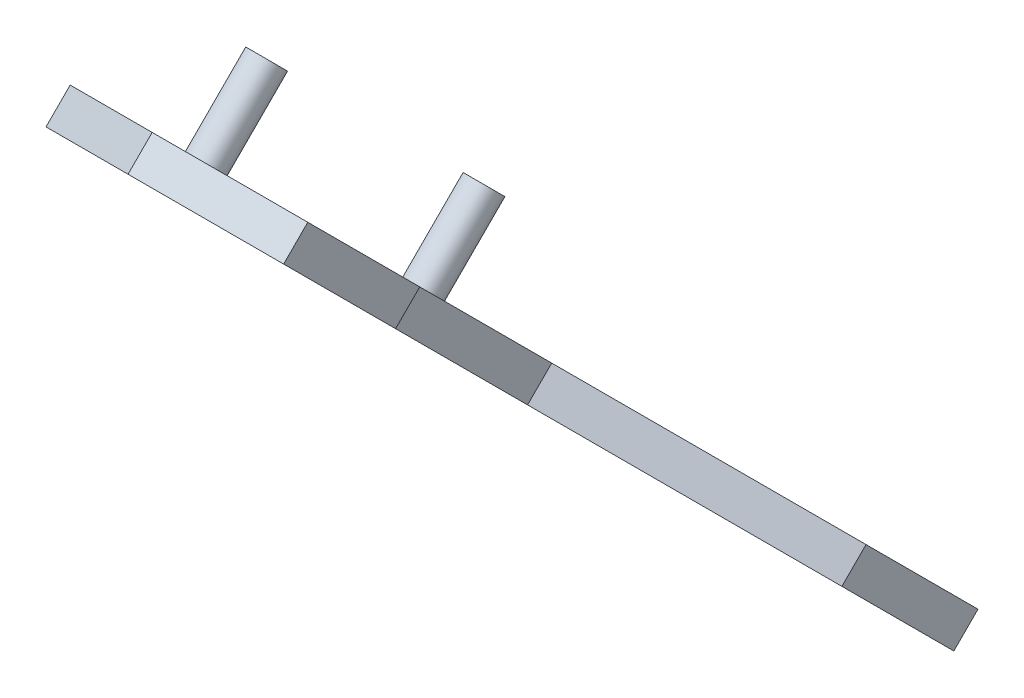
from build123d import *

# Parameters (mm, degrees)
BOSS_EXTRUDE1_DEPTH      = 5
BOSS_EXTRUDE1_DEPTH_BACK = 100
BOSS_EXTRUDE1_START      = -23110
SKETCH3_W                = 150.118051911
SKETCH3_H                = 92.714651823
BOSS_EXTRUDE2_DEPTH      = 20
SKETCH4_R                = 10
BOSS_EXTRUDE3_DEPTH      = 50
CUT_EXTRUDE1_DEPTH       = 38501.104645459
BOSS_EXTRUDE4_DEPTH      = 20


with BuildPart() as part:
    # Sketch2 → Boss-Extrude1 (new, two sides: drawn at the far end of the back side and taken through both)
    with BuildSketch(Plane(origin=(0, 0, 0), x_dir=(0, 0, -1), z_dir=(1, 0, 0)).offset(BOSS_EXTRUDE1_START - BOSS_EXTRUDE1_DEPTH_BACK)):
        Polygon((-40429.816686048, 2996.894248022), (-40037.372422489, 2604.449984464), (-40023.230286866, 2618.592120087), (-40415.674550424, 3011.036383646), align=None)
    extrude(amount=BOSS_EXTRUDE1_DEPTH + BOSS_EXTRUDE1_DEPTH_BACK)

    # Sketch3 → Boss-Extrude2 (add)
    with BuildSketch(Plane(origin=(0, -18716.461219013, 18716.461219015), x_dir=(1, 0, 0), z_dir=(0, -0.7071067811865143, 0.7071067811865808))):
        with Locations((-23029.940974045, 30660.964460197)):
            Rectangle(SKETCH3_W, SKETCH3_H)
        with Locations((-23029.940974045, 30198.67911202)):
            Rectangle(SKETCH3_W, SKETCH3_H)
    extrude(amount=-BOSS_EXTRUDE2_DEPTH)

    # Sketch4 → Boss-Extrude3 (add)
    with BuildSketch(Plane(origin=(0, -18702.319083389, 18702.319083389), x_dir=(1, 0, 0), z_dir=(0, 0.7071067811865416, -0.7071067811865535))):
        with Locations((-23146.230449039, -30340.794679614)):
            Circle(SKETCH4_R)
        with Locations((-23146.230449039, -30520.794679614)):
            Circle(SKETCH4_R)
    extrude(amount=BOSS_EXTRUDE3_DEPTH)

    # Sketch7 → Cut-Extrude1 (cut, through all)
    with BuildSketch(Plane(origin=(0, -18716.461219013, 18716.461219015), x_dir=(1, 0, 0), z_dir=(0, -0.7071067811865143, 0.7071067811865808))):
        Polygon((-23210, 30152.321786108), (-23046, 30152.321786108), (-23210, 30316.321786108), align=None)
        Polygon((-23210, 30707.321786108), (-23210, 30543.321786108), (-23046, 30707.321786108), align=None)
    extrude(amount=-CUT_EXTRUDE1_DEPTH, mode=Mode.SUBTRACT)


with BuildPart() as body_2:
    # Sketch7_3 → Boss-Extrude4 (new body)
    with BuildSketch(Plane(origin=(0, -18716.461219013, 18716.461219015), x_dir=(1, 0, 0), z_dir=(0, -0.7071067811865143, 0.7071067811865808))):
        Polygon((-23105, 30245.036437931), (-22954.881948089, 30245.036437931), (-23062.696263559, 30352.850753401), (-23062.696263559, 30506.792818814), (-22954.881948089, 30614.607134285), (-23105, 30614.607134285), align=None)
    extrude(amount=-BOSS_EXTRUDE4_DEPTH)


solid = Compound([part.part, body_2.part])
